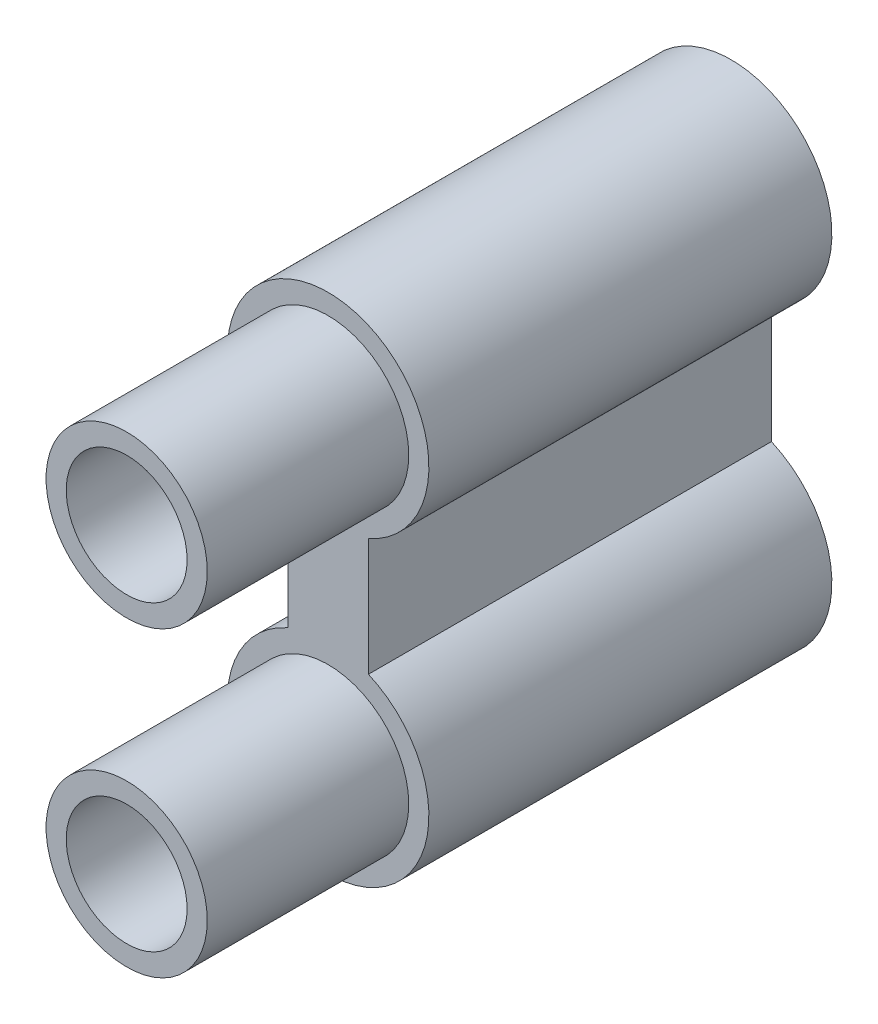
from build123d import *

# Parameters (mm, degrees)
ESQUISSE1_R             = 15
BOSS_EXTRU_1_DEPTH      = 150
ESQUISSE3_OUTSIDE_W     = 92.312
ESQUISSE3_OUTSIDE_H     = 167.312
ESQUISSE3_OUTSIDE_R     = 20
ENL_V_MAT_EXTRU_2_DEPTH = 50


with BuildPart() as part:
    # Esquisse1 → Boss.-Extru.1 (new body)
    with BuildSketch(Plane.XY):
        with BuildLine():
            Line((-10, 52.087121525), (-10, 22.912878475))
            ThreePointArc((-10, 22.912878475), (0, -25), (10, 22.912878475))
            Line((10, 22.912878475), (10, 52.087121525))
            ThreePointArc((10, 52.087121525), (0, 100), (-10, 52.087121525))
        make_face()
        Circle(ESQUISSE1_R, mode=Mode.SUBTRACT)
        with Locations((0, 75)):
            Circle(ESQUISSE1_R, mode=Mode.SUBTRACT)
    extrude(amount=BOSS_EXTRU_1_DEPTH)

    # Esquisse3 outside → Enlèv. mat.-Extru.2 (cut)
    with BuildSketch(Plane.XY.offset(150)):
        with Locations((0, 37.5)):
            Rectangle(ESQUISSE3_OUTSIDE_W, ESQUISSE3_OUTSIDE_H)
        with Locations((0, 75)):
            Circle(ESQUISSE3_OUTSIDE_R, mode=Mode.SUBTRACT)
        Circle(ESQUISSE3_OUTSIDE_R, mode=Mode.SUBTRACT)
    extrude(amount=-ENL_V_MAT_EXTRU_2_DEPTH, mode=Mode.SUBTRACT)


solid = part.part
